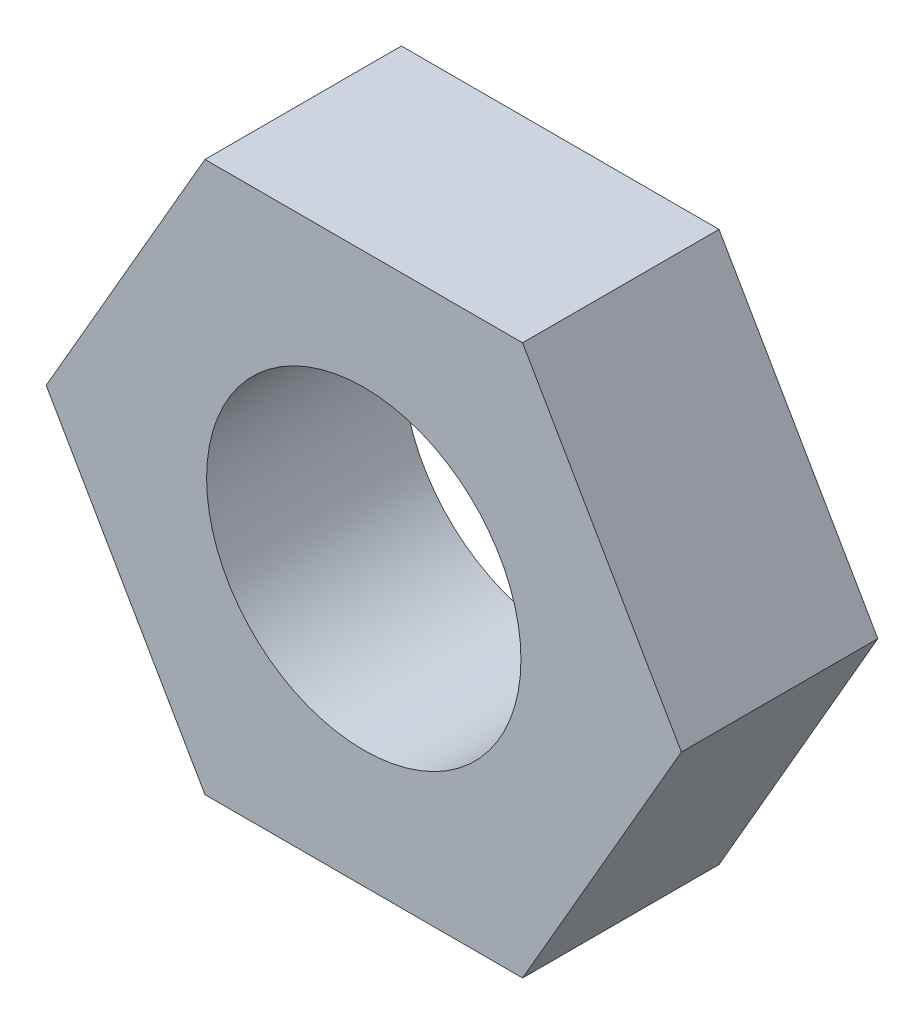
from build123d import *

# Parameters (mm, degrees)
CROQUIS1_R              = 2
SALIENTE_EXTRUIR1_DEPTH = 2.5


with BuildPart() as part:
    # Croquis1 → Saliente-Extruir1 (new body)
    with BuildSketch(Plane.XY):
        Polygon((4.041451884, 0), (2.020725942, 3.5), (-2.020725942, 3.5), (-4.041451884, 0), (-2.020725942, -3.5), (2.020725942, -3.5), align=None)
        Circle(CROQUIS1_R, mode=Mode.SUBTRACT)
    extrude(amount=SALIENTE_EXTRUIR1_DEPTH)


solid = part.part
